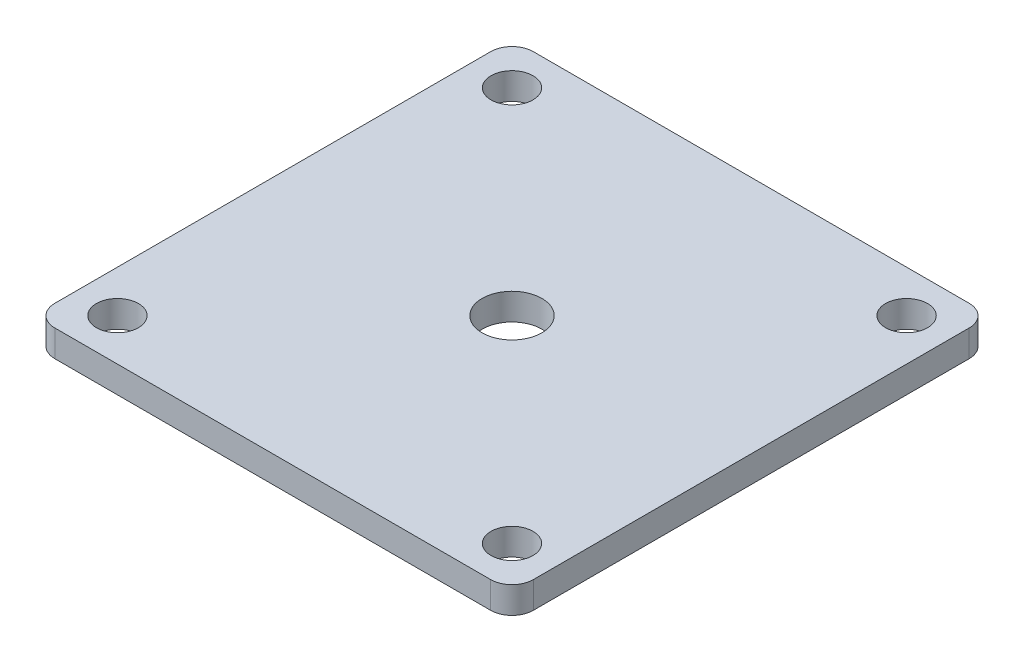
from build123d import *

# Parameters (mm, degrees)
SKETCH1_R           = 3.556
SKETCH1_R_2         = 2.499995
BOSS_EXTRUDE1_DEPTH = 3.175


with BuildPart() as part:
    # Sketch1 → Boss-Extrude1 (new body)
    with BuildSketch(Plane(origin=(0, 0, 0), x_dir=(1, 0, 0), z_dir=(0, 1, 0))):
        with BuildLine():
            Line((-13.993314597, 28.4999938), (-25.9599938, 28.4999938))
            ThreePointArc((-25.9599938, 28.4999938), (-27.756045024, 27.756045024), (-28.4999938, 25.9599938))
            Line((-28.4999938, 25.9599938), (-28.4999938, 13.993314597))
            Line((-28.4999938, 13.993314597), (-28.4999938, -13.993314597))
            Line((-28.4999938, -13.993314597), (-28.4999938, -25.9599938))
            ThreePointArc((-28.4999938, -25.9599938), (-27.756045024, -27.756045024), (-25.9599938, -28.4999938))
            Line((-25.9599938, -28.4999938), (-13.993314597, -28.4999938))
            Line((-13.993314597, -28.4999938), (13.993314597, -28.4999938))
            Line((13.993314597, -28.4999938), (25.9599938, -28.4999938))
            ThreePointArc((25.9599938, -28.4999938), (27.756045024, -27.756045024), (28.4999938, -25.9599938))
            Line((28.4999938, -25.9599938), (28.4999938, -13.993314597))
            Line((28.4999938, -13.993314597), (28.4999938, 13.993314597))
            Line((28.4999938, 13.993314597), (28.4999938, 25.9599938))
            ThreePointArc((28.4999938, 25.9599938), (27.756045024, 27.756045024), (25.9599938, 28.4999938))
            Line((25.9599938, 28.4999938), (13.993314597, 28.4999938))
            Line((13.993314597, 28.4999938), (-13.993314597, 28.4999938))
        make_face()
        Circle(SKETCH1_R, mode=Mode.SUBTRACT)
        with Locations((-23.5000038, 23.5000038)):
            Circle(SKETCH1_R_2, mode=Mode.SUBTRACT)
        with Locations((23.5000038, 23.5000038)):
            Circle(SKETCH1_R_2, mode=Mode.SUBTRACT)
        with Locations((23.5000038, -23.5000038)):
            Circle(SKETCH1_R_2, mode=Mode.SUBTRACT)
        with Locations((-23.5000038, -23.5000038)):
            Circle(SKETCH1_R_2, mode=Mode.SUBTRACT)
    extrude(amount=BOSS_EXTRUDE1_DEPTH)


solid = part.part
